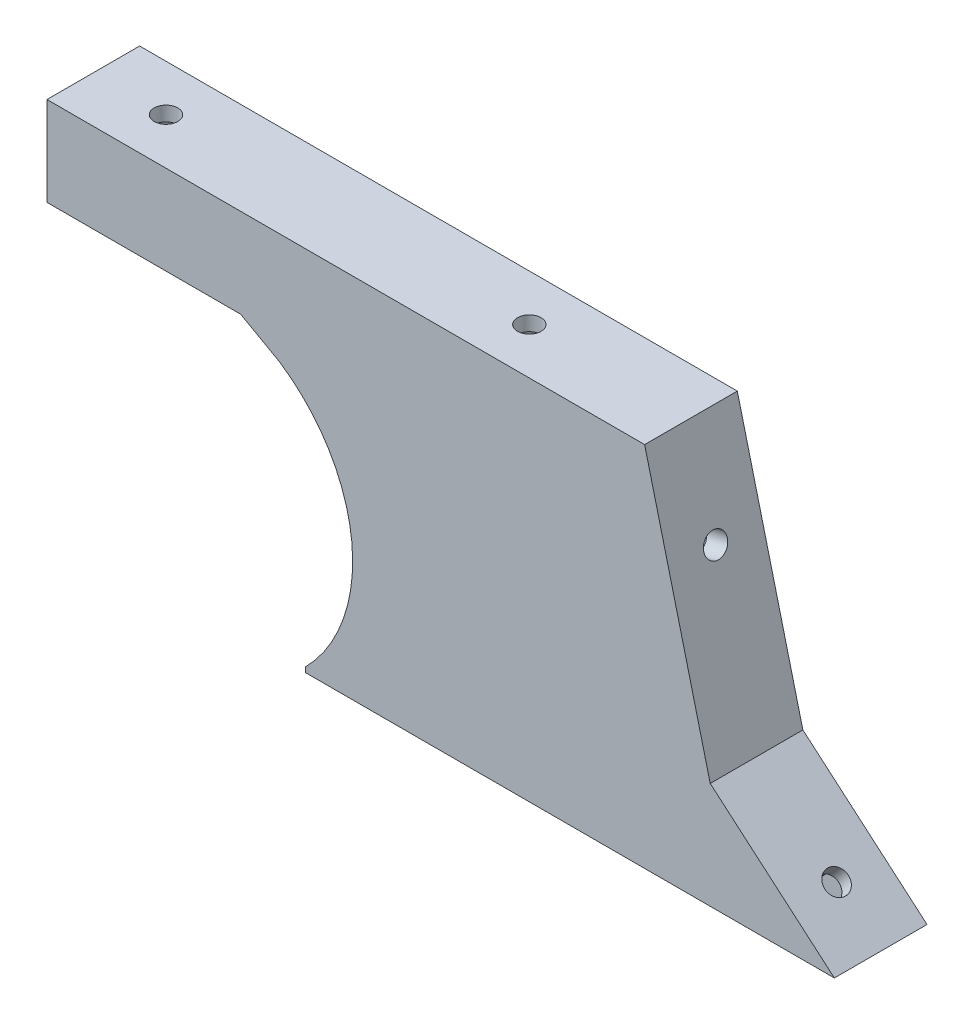
from build123d import *

# Parameters (mm, degrees)
SALIENTE_EXTRUIR1_DEPTH = 3
SALIENTE_EXTRUIR2_DEPTH = 9.75
CROQUIS6_R              = 1.625
CORTAR_EXTRUIR1_DEPTH   = 5
CORTAR_EXTRUIR2_DEPTH   = 2
CORTAR_EXTRUIR4_DEPTH   = 10
CROQUIS10_R             = 1.625
SALIENTE_EXTRUIR3_DEPTH = 2
CROQUIS12_R             = 1.625
CORTAR_EXTRUIR5_DEPTH   = 5
CORTAR_EXTRUIR6_DEPTH   = 2
CROQUIS14_R             = 1.625
CORTAR_EXTRUIR7_DEPTH   = 4
CORTAR_EXTRUIR8_DEPTH   = 2
CROQUIS17_R             = 1.625
CORTAR_EXTRUIR9_DEPTH   = 4
CORTAR_EXTRUIR10_DEPTH  = 2


with BuildPart() as part:
    # Croquis1 → Saliente-Extruir1 (new body)
    with BuildSketch(Plane.XY):
        with BuildLine():
            Line((0, 0.68070798), (0, 0))
            Line((0, 0), (72.78319995, 0))
            Line((72.78319995, 0), (55.699999998, 14.642073221))
            Line((55.699999998, 14.642073221), (46.67593732, 50.511923567))
            Line((46.67593732, 50.511923567), (-35.562657036, 50.511923567))
            Line((-35.562657036, 50.511923567), (-35.562657036, 38.25))
            Line((-35.562657036, 38.25), (-8.913300435, 38.25))
            Line((-8.913300435, 38.25), (-3.562657036, 35.25))
            ThreePointArc((-3.562657036, 35.25), (6.381456753, 18.806597842), (0, 0.68070798))
        make_face()
    extrude(amount=-SALIENTE_EXTRUIR1_DEPTH)

    # Croquis5 → Saliente-Extruir2 (add)
    with BuildSketch(Plane(origin=(0, 0, -3), x_dir=(-1, 0, 0), z_dir=(0, 0, -1))):
        with BuildLine():
            Line((-51.238983488, 11.880365447), (-59.266443595, 5))
            Line((-59.266443595, 5), (-3.339079606, 5))
            ThreePointArc((-3.339079606, 5), (-1.801031086, 2.738703104), (0, 0.68070798))
            Line((0, 0.68070798), (0, 0))
            Line((0, 0), (-72.78319995, 0))
            Line((-72.78319995, 0), (-55.699999998, 14.642073221))
            Line((-55.699999998, 14.642073221), (-46.67593732, 50.511923567))
            Line((-46.67593732, 50.511923567), (35.562657036, 50.511923567))
            Line((35.562657036, 50.511923567), (35.562657036, 38.25))
            Line((35.562657036, 38.25), (31.562657036, 38.25))
            Line((31.562657036, 38.25), (31.562657036, 46.511923567))
            Line((31.562657036, 46.511923567), (-42.526447804, 46.511923567))
            Line((-42.526447804, 46.511923567), (-51.238983488, 11.880365447))
        make_face()
    extrude(amount=SALIENTE_EXTRUIR2_DEPTH)

    # Croquis6 → Cortar-Extruir1 (cut)
    with BuildSketch(Plane.XZ):
        with Locations((6.999999998, -7)):
            Circle(CROQUIS6_R)
        with Locations((52.78319995, -7)):
            Circle(CROQUIS6_R)
    extrude(amount=-CORTAR_EXTRUIR1_DEPTH, mode=Mode.SUBTRACT)

    # Croquis8 → Cortar-Extruir2 (cut)
    with BuildSketch(Plane(origin=(0, 5, 0), x_dir=(1, 0, 0), z_dir=(0, 1, 0))):
        Polygon((3.819999998, 7), (5.409999998, 4.246039216), (8.589999998, 4.246039216), (10.179999998, 7), (8.589999998, 9.753960784), (5.409999998, 9.753960784), align=None)
        Polygon((49.60319995, 7), (51.19319995, 4.246039216), (54.37319995, 4.246039216), (55.96319995, 7), (54.37319995, 9.753960784), (51.19319995, 9.753960784), align=None)
    extrude(amount=-CORTAR_EXTRUIR2_DEPTH, mode=Mode.SUBTRACT)

    # Croquis9 → Cortar-Extruir4 (cut)
    with BuildSketch(Plane(origin=(30.824200619, 35.963211942, 0), x_dir=(0.759271307, -0.650774217, 0), z_dir=(0.650774217, 0.759271307, 0))):
        Polygon((50.442195378, 6.375), (48.852195378, 9.128960784), (45.672195378, 9.128960784), (44.082195378, 6.375), (45.672195378, 3.621039216), (48.852195378, 3.621039216), align=None)
    extrude(amount=-CORTAR_EXTRUIR4_DEPTH, mode=Mode.SUBTRACT)

    # Croquis10 → Saliente-Extruir3 (add)
    with BuildSketch(Plane(origin=(30.824200619, 35.963211942, 0), x_dir=(0.759271307, -0.650774217, 0), z_dir=(0.650774217, 0.759271307, 0))):
        Polygon((50.442195378, 6.375), (48.852195378, 9.128960784), (45.672195378, 9.128960784), (44.082195378, 6.375), (45.672195378, 3.621039216), (48.852195378, 3.621039216), align=None)
        with Locations((47.262195378, 6.375)):
            Circle(CROQUIS10_R, mode=Mode.SUBTRACT)
    extrude(amount=-SALIENTE_EXTRUIR3_DEPTH)

    # Croquis12 → Cortar-Extruir5 (cut)
    with BuildSketch(Plane(origin=(55.848866467, 14.050342186, 0), x_dir=(0, 0, -1), z_dir=(0.969781373, 0.24397559, 0))):
        with Locations((6.375, 23.727396855)):
            Circle(CROQUIS12_R)
    extrude(amount=-CORTAR_EXTRUIR5_DEPTH, mode=Mode.SUBTRACT)

    # Croquis13 → Cortar-Extruir6 (cut)
    with BuildSketch(Plane(origin=(50.999959602, 12.830464236, 0), x_dir=(0, 0, 1), z_dir=(-0.969781373, -0.24397559, 0))):
        Polygon((-6.375, 20.547396855), (-3.621039216, 22.137396855), (-3.621039216, 25.317396855), (-6.375, 26.907396855), (-9.128960784, 25.317396855), (-9.128960784, 22.137396855), align=None)
    extrude(amount=-CORTAR_EXTRUIR6_DEPTH, mode=Mode.SUBTRACT)

    # Croquis14 → Cortar-Extruir7 (cut)
    with BuildSketch(Plane(origin=(0, 50.511923567, 0), x_dir=(1, 0, 0), z_dir=(0, 1, 0))):
        with Locations((-25.562657036, 6.375)):
            Circle(CROQUIS14_R)
        with Locations((24.437342964, 6.375)):
            Circle(CROQUIS14_R)
    extrude(amount=-CORTAR_EXTRUIR7_DEPTH, mode=Mode.SUBTRACT)

    # Croquis15 → Cortar-Extruir8 (cut)
    with BuildSketch(Plane.XZ.offset(-46.511923567)):
        Polygon((-22.382657036, -6.375), (-23.972657036, -3.621039216), (-27.152657036, -3.621039216), (-28.742657036, -6.375), (-27.152657036, -9.128960784), (-23.972657036, -9.128960784), align=None)
        Polygon((21.257342964, -6.375), (22.847342964, -9.128960784), (26.027342964, -9.128960784), (27.617342964, -6.375), (26.027342964, -3.621039216), (22.847342964, -3.621039216), align=None)
    extrude(amount=-CORTAR_EXTRUIR8_DEPTH, mode=Mode.SUBTRACT)

    # Croquis17 → Cortar-Extruir9 (cut)
    with BuildSketch(Plane.ZY.offset(35.562657036)):
        with Locations((-7.982505966, 42.38)):
            Circle(CROQUIS17_R)
    extrude(amount=-CORTAR_EXTRUIR9_DEPTH, mode=Mode.SUBTRACT)

    # Croquis18 → Cortar-Extruir10 (cut)
    with BuildSketch(Plane(origin=(-31.562657036, 0, 0), x_dir=(0, 0, -1), z_dir=(1, 0, 0))):
        Polygon((7.982505966, 39.2), (10.73646675, 40.79), (10.73646675, 43.97), (7.982505966, 45.56), (5.228545182, 43.97), (5.228545182, 40.79), align=None)
    extrude(amount=-CORTAR_EXTRUIR10_DEPTH, mode=Mode.SUBTRACT)


solid = part.part
